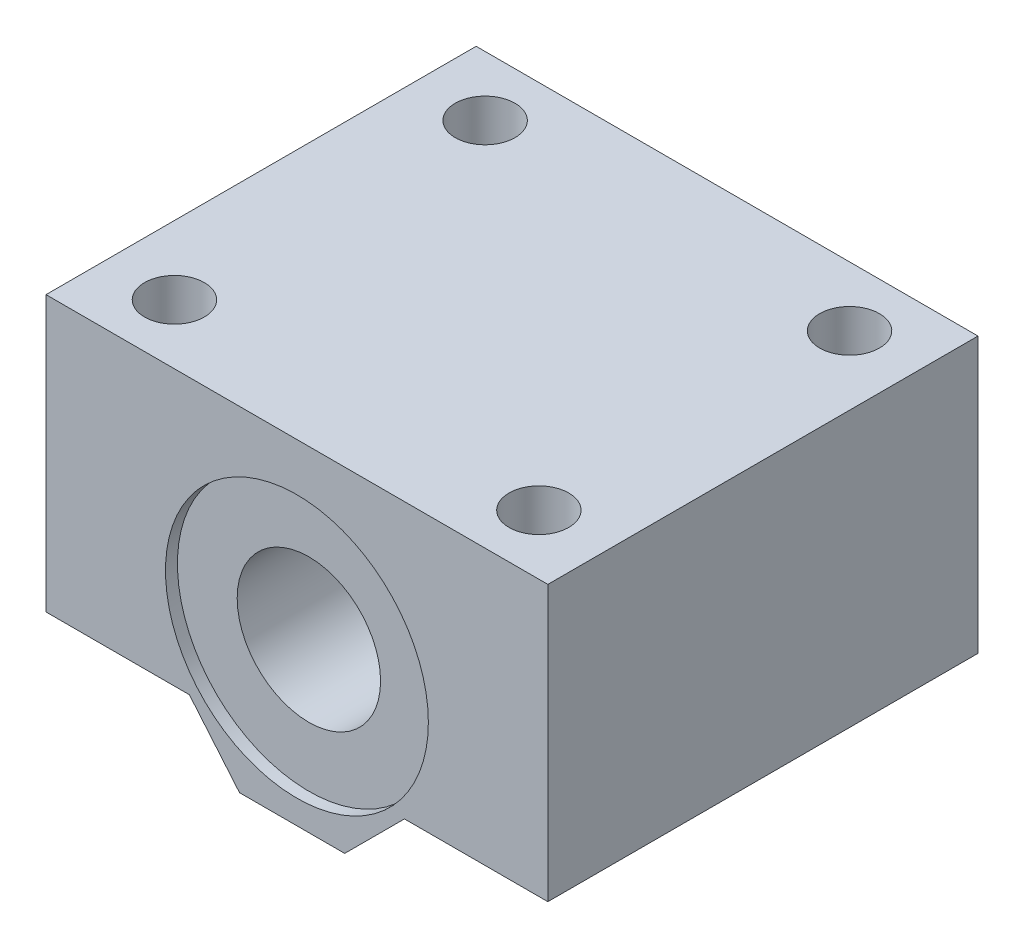
from build123d import *

# Parameters (mm, degrees)
SKETCH1_W           = 42
SKETCH1_H           = 28
SKETCH1_R           = 6
BOSS_EXTRUDE1_DEPTH = 18
CUT_EXTRUDE5_DEPTH  = 37
SKETCH2_R           = 2.15
CUT_EXTRUDE1_DEPTH  = 29
SKETCH3_R           = 2.5
CUT_EXTRUDE2_DEPTH  = 12
SKETCH4_R           = 11
CUT_EXTRUDE3_DEPTH  = 1
SKETCH5_R           = 11
CUT_EXTRUDE4_DEPTH  = 1


with BuildPart() as part:
    # Sketch1 → Boss-Extrude1 (new body, symmetric)
    with BuildSketch(Plane.XY):
        Rectangle(SKETCH1_W, SKETCH1_H)
        with Locations((0, -1)):
            Circle(SKETCH1_R, mode=Mode.SUBTRACT)
    extrude(amount=BOSS_EXTRUDE1_DEPTH, both=True)

    # Sketch6 → Cut-Extrude5 (cut, through all)
    with BuildSketch(Plane.XY.offset(18)):
        Polygon((-21, -9), (-9, -9), (-4.804501844, -14), (-21, -14), align=None)
        Polygon((21, -9), (9, -9), (4, -14), (21, -14), align=None)
    extrude(amount=-CUT_EXTRUDE5_DEPTH, mode=Mode.SUBTRACT)

    # Sketch2 → Cut-Extrude1 (cut, through all)
    with BuildSketch(Plane(origin=(0, 14, 0), x_dir=(-1, 0, 0), z_dir=(0, -1, 0))):
        with Locations((15.25, -13)):
            Circle(SKETCH2_R)
        with Locations((-15.25, -13)):
            Circle(SKETCH2_R)
        with Locations((-15.25, 13)):
            Circle(SKETCH2_R)
        with Locations((15.25, 13)):
            Circle(SKETCH2_R)
    extrude(amount=CUT_EXTRUDE1_DEPTH, mode=Mode.SUBTRACT)

    # Sketch3 → Cut-Extrude2 (cut)
    with BuildSketch(Plane.XZ.offset(-14)):
        with Locations((-15.25, 13)):
            Circle(SKETCH3_R)
        with Locations((15.25, 13)):
            Circle(SKETCH3_R)
        with Locations((15.25, -13)):
            Circle(SKETCH3_R)
        with Locations((-15.25, -13)):
            Circle(SKETCH3_R)
    extrude(amount=CUT_EXTRUDE2_DEPTH, mode=Mode.SUBTRACT)

    # Sketch4 → Cut-Extrude3 (cut)
    with BuildSketch(Plane.XY.offset(18)):
        with Locations((0, -1)):
            Circle(SKETCH4_R)
    extrude(amount=-CUT_EXTRUDE3_DEPTH, mode=Mode.SUBTRACT)

    # Sketch5 → Cut-Extrude4 (cut)
    with BuildSketch(Plane(origin=(0, 0, -18), x_dir=(-1, 0, 0), z_dir=(0, 0, -1))):
        with Locations((0, -1)):
            Circle(SKETCH5_R)
    extrude(amount=-CUT_EXTRUDE4_DEPTH, mode=Mode.SUBTRACT)


solid = part.part
